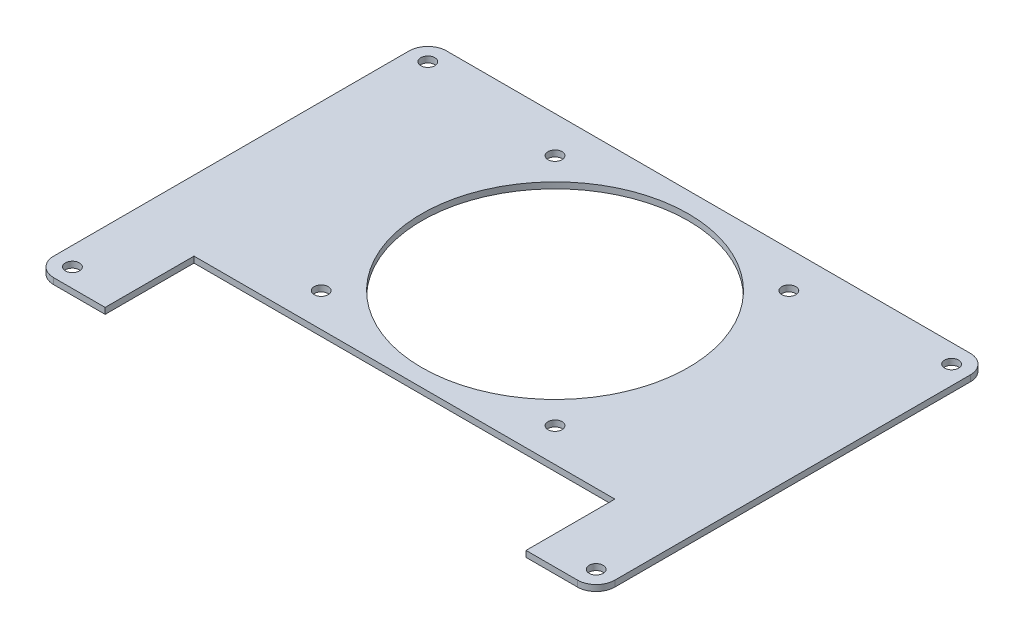
from build123d import *

# Parameters (mm, degrees)
SKETCH1_R           = 1.5
BOSS_EXTRUDE1_DEPTH = 1.3
SKETCH2_R           = 28.5
SKETCH2_R_2         = 1.5
SKETCH2_W           = 90
SKETCH2_H           = 19
CUT_EXTRUDE1_DEPTH  = 10


with BuildPart() as part:
    # Sketch1 → Boss-Extrude1 (new body)
    with BuildSketch(Plane(origin=(0, 0, 0), x_dir=(1, 0, 0), z_dir=(0, 1, 0))):
        with BuildLine():
            Line((-56, -42), (56, -42))
            ThreePointArc((56, -42), (58.828427125, -40.828427125), (60, -38))
            Line((60, -38), (60, 38))
            ThreePointArc((60, 38), (58.828427125, 40.828427125), (56, 42))
            Line((56, 42), (-56, 42))
            ThreePointArc((-56, 42), (-58.828427125, 40.828427125), (-60, 38))
            Line((-60, 38), (-60, -38))
            ThreePointArc((-60, -38), (-58.828427125, -40.828427125), (-56, -42))
        make_face()
        with Locations((-56, 38)):
            Circle(SKETCH1_R, mode=Mode.SUBTRACT)
        with Locations((56, 38)):
            Circle(SKETCH1_R, mode=Mode.SUBTRACT)
        with Locations((56, -38)):
            Circle(SKETCH1_R, mode=Mode.SUBTRACT)
        with Locations((-56, -38)):
            Circle(SKETCH1_R, mode=Mode.SUBTRACT)
    extrude(amount=BOSS_EXTRUDE1_DEPTH)

    # Sketch2 → Cut-Extrude1 (cut)
    with BuildSketch(Plane(origin=(0, 1.3, 0), x_dir=(1, 0, 0), z_dir=(0, 1, 0))):
        with Locations((0, 9.2)):
            Circle(SKETCH2_R)
        with Locations((-25, 34.2)):
            Circle(SKETCH2_R_2)
        with Locations((25, 34.2)):
            Circle(SKETCH2_R_2)
        with Locations((25, -15.8)):
            Circle(SKETCH2_R_2)
        with Locations((-25, -15.8)):
            Circle(SKETCH2_R_2)
        with Locations((0, -32.5)):
            Rectangle(SKETCH2_W, SKETCH2_H)
    extrude(amount=-CUT_EXTRUDE1_DEPTH, mode=Mode.SUBTRACT)


solid = part.part
